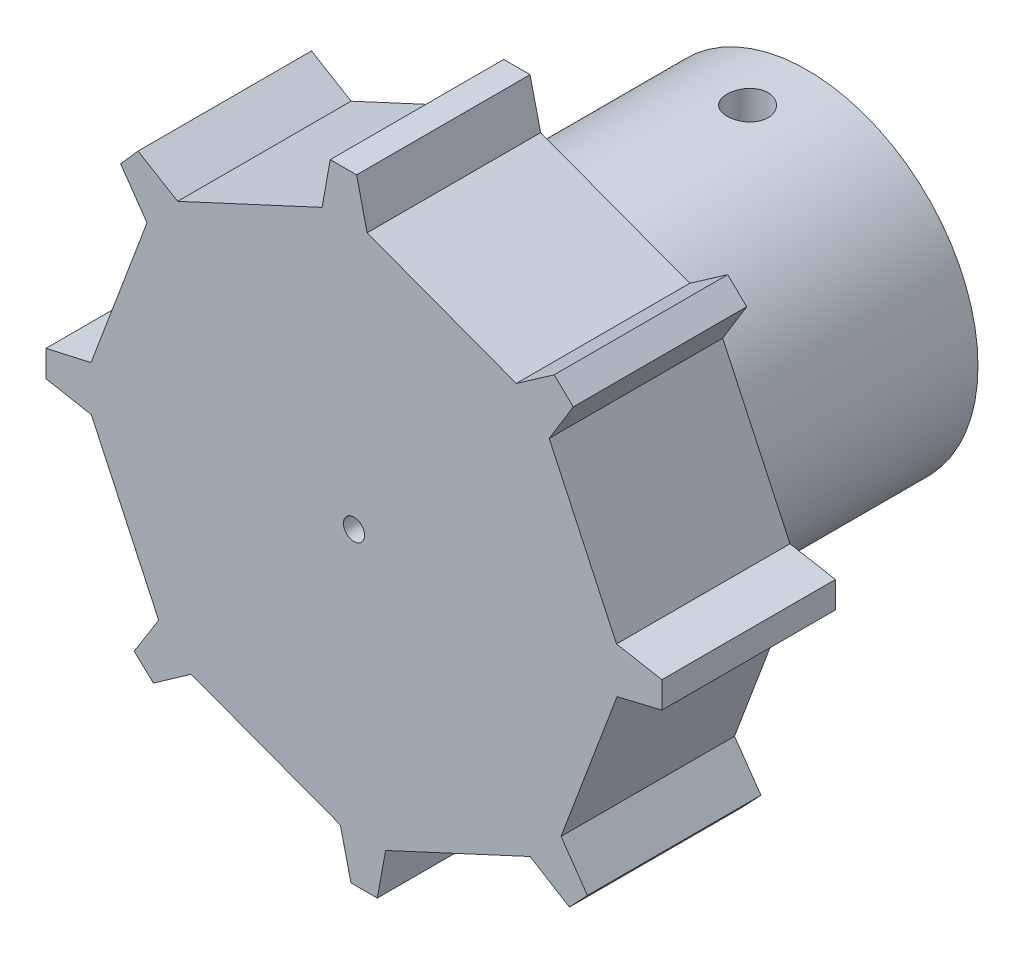
from build123d import *

# Parameters (mm, degrees)
BOSS_EXTRUDE1_DEPTH     = 12.7
CUT_EXTRUDE1_REACH      = 14.7
SKETCH2_R               = 0.775
SKETCH4_R               = 12.5
SKETCH4_R_2             = 2.75
BOSS_EXTRUDE3_DEPTH     = 20.5
BOSS_EXTRUDE4_DEPTH     = 20.5
SKETCH5_R               = 1.5
CUT_EXTRUDE2_DEPTH      = 12
CUT_EXTRUDE2_DEPTH_BACK = 2
CUT_EXTRUDE3_DEPTH      = 17


with BuildPart() as part:
    # Sketch1 → Boss-Extrude1 (new body)
    with BuildSketch(Plane(origin=(0, 0, 0), x_dir=(-1, 0, 0), z_dir=(0, 0, -1))):
        Polygon((22.52557458, -1.736588639), (22.52557458, 0.194536921), (19.229808022, 0.93665661), (15.128723263, 11.851737372), (17.063649078, 14.621011813), (15.786423571, 16.069438867), (12.890863827, 14.329165151), (2.313040546, 19.235032954), (1.719665356, 22.560799741), (-0.211460204, 22.560799741), (-0.98374926, 19.271971918), (-11.902473648, 15.180597821), (-14.673902719, 17.112436257), (-16.073066924, 15.781427071), (-14.308800518, 12.900423272), (-19.236913758, 2.332945609), (-22.560976284, 1.730096406), (-22.560976284, -0.201029153), (-19.275488766, -0.987407309), (-15.174404006, -11.902488071), (-17.112216048, -14.669743631), (-15.788139908, -16.075470597), (-12.910837913, -14.305173427), (-2.333014633, -19.21104123), (-1.727718406, -22.534659035), (0.203407153, -22.534659035), (0.978499423, -19.246490729), (11.89722381, -15.155116632), (14.659649692, -17.099807376), (16.072878525, -15.783741196), (14.276312796, -12.922767512), (19.204426036, -2.355289849), align=None)
    extrude(amount=-BOSS_EXTRUDE1_DEPTH)

    # Sketch2 → Cut-Extrude1 (cut, up to next)
    with BuildSketch(Plane(origin=(0, 0, 0), x_dir=(-1, 0, 0), z_dir=(0, 0, -1)), mode=Mode.PRIVATE) as cut_extrude1_sk1:
        with Locations((-0.019773646, -0.00956531)):
            Circle(SKETCH2_R)
    cut_extrude1_tool1 = extrude(cut_extrude1_sk1.sketch, amount=-CUT_EXTRUDE1_REACH, mode=Mode.PRIVATE) & part.part
    add(cut_extrude1_tool1.solids().sort_by_distance((0.019774, -0.009565, 0))[0], mode=Mode.SUBTRACT)

    # Sketch4 → Boss-Extrude3 (add)
    with BuildSketch(Plane(origin=(0, 0, 0), x_dir=(-1, 0, 0), z_dir=(0, 0, -1))):
        Circle(SKETCH4_R)
        Circle(SKETCH4_R_2, mode=Mode.SUBTRACT)
    extrude(amount=BOSS_EXTRUDE3_DEPTH)

    # Sketch4_4 → Boss-Extrude4 (add)
    with BuildSketch(Plane(origin=(0, 0, 0), x_dir=(-1, 0, 0), z_dir=(0, 0, -1))):
        with BuildLine():
            Line((-0.567488363, 2.690809722), (0.726565511, 2.652282518))
            ThreePointArc((0.726565511, 2.652282518), (0.081838079, 2.748782008), (-0.567488363, 2.690809722))
        make_face()
    extrude(amount=BOSS_EXTRUDE4_DEPTH)

    # Sketch5 → Cut-Extrude2 (cut, two sides)
    with BuildSketch(Plane(origin=(0, 4, 0), x_dir=(1, 0, 0), z_dir=(0, 1, 0))) as cut_extrude2_sk:
        with Locations((0, 16.130068411)):
            Circle(SKETCH5_R)
    extrude(amount=CUT_EXTRUDE2_DEPTH, mode=Mode.SUBTRACT)
    extrude(cut_extrude2_sk.sketch, amount=-CUT_EXTRUDE2_DEPTH_BACK, mode=Mode.SUBTRACT)

    # Sketch6 → Cut-Extrude3 (cut)
    with BuildSketch(Plane(origin=(0, 0, -20.5), x_dir=(-1, 0, 0), z_dir=(0, 0, -1))):
        Polygon((4.579538574, 7.537569925), (-4.420461426, 7.805522315), (-4.538346431, 3.845994095), (4.461653569, 3.578041705), align=None)
    extrude(amount=-CUT_EXTRUDE3_DEPTH, mode=Mode.SUBTRACT)


solid = part.part
